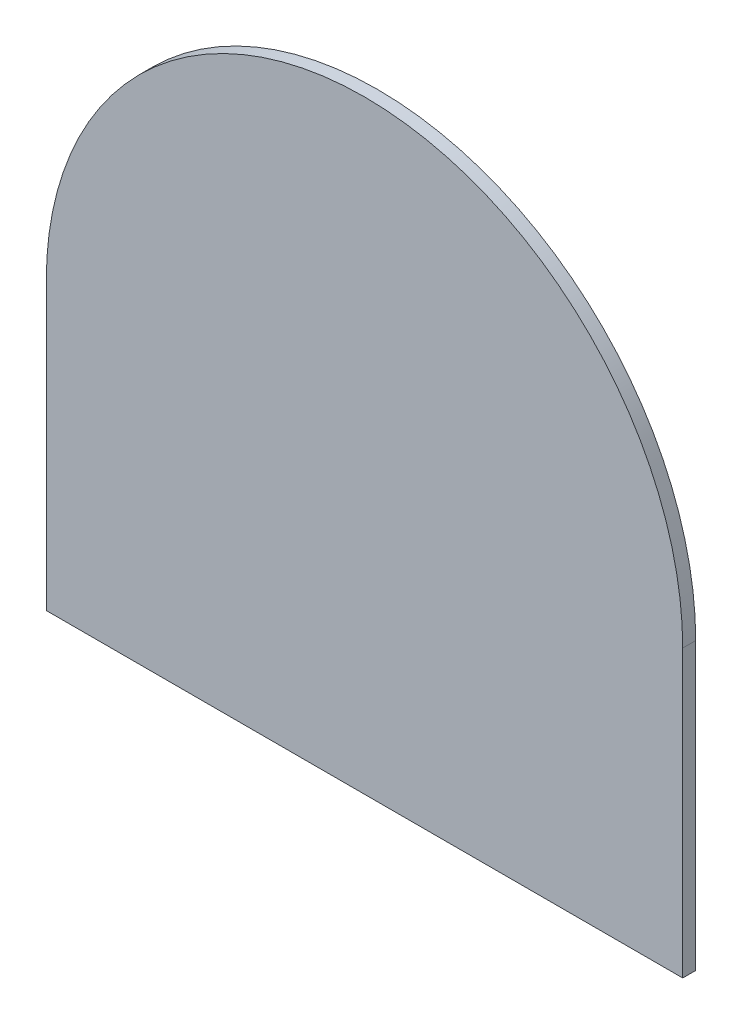
from build123d import *

# Parameters (mm, degrees)
BOSS_EXTRU_1_DEPTH = 1


with BuildPart() as part:
    # Esquisse1 → Boss.-Extru.1 (new body)
    with BuildSketch(Plane.XY):
        with BuildLine():
            Line((0, 0), (49, 0))
            Line((49, 0), (49, 22))
            ThreePointArc((49, 22), (41.824116139, 39.324116139), (24.5, 46.5))
            ThreePointArc((24.5, 46.5), (7.175883861, 39.324116139), (0, 22))
            Line((0, 22), (0, 0))
        make_face()
    extrude(amount=BOSS_EXTRU_1_DEPTH)


solid = part.part
